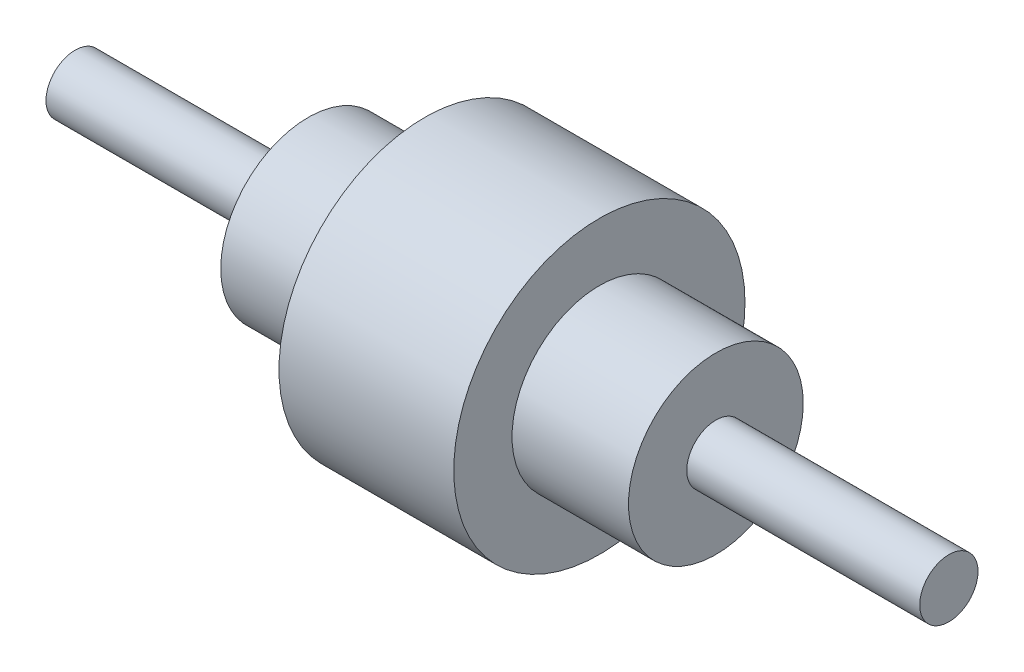
from build123d import *

# Parameters (mm, degrees)
SKETCH1_R           = 50
BOSS_EXTRUDE1_DEPTH = 30
SKETCH2_R           = 30
BOSS_EXTRUDE2_DEPTH = 30
SKETCH3_R           = 10
BOSS_EXTRUDE3_DEPTH = 80
SKETCH7_R           = 30
BOSS_EXTRUDE4_DEPTH = 10
SKETCH8_R           = 10
BOSS_EXTRUDE5_DEPTH = 10
SKETCH9_R           = 30
BOSS_EXTRUDE6_DEPTH = 10
SKETCH10_R          = 10
BOSS_EXTRUDE7_DEPTH = 10


with BuildPart() as part:
    # Sketch1 → Boss-Extrude1 (new body)
    with BuildSketch(Plane(origin=(0, 0, 0), x_dir=(0, 0, -1), z_dir=(1, 0, 0))):
        Circle(SKETCH1_R)
    boss_extrude1 = extrude(amount=BOSS_EXTRUDE1_DEPTH)

    # Sketch2 → Boss-Extrude2 (add)
    with BuildSketch(Plane(origin=(30, 0, 0), x_dir=(0, 0, -1), z_dir=(1, 0, 0))):
        Circle(SKETCH2_R)
    boss_extrude2 = extrude(amount=BOSS_EXTRUDE2_DEPTH)

    # Sketch3 → Boss-Extrude3 (add)
    with BuildSketch(Plane(origin=(60, 0, 0), x_dir=(0, 0, -1), z_dir=(1, 0, 0))):
        Circle(SKETCH3_R)
    boss_extrude3 = extrude(amount=BOSS_EXTRUDE3_DEPTH)

    # Mirror1: Boss-Extrude1, Boss-Extrude2, Boss-Extrude3 across plane
    add(boss_extrude1.mirror(Plane(origin=(0, 0, 0), x_dir=(0, 0, 1), z_dir=(1, 0, 0))))
    add(boss_extrude2.mirror(Plane(origin=(0, 0, 0), x_dir=(0, 0, 1), z_dir=(1, 0, 0))))
    add(boss_extrude3.mirror(Plane(origin=(0, 0, 0), x_dir=(0, 0, 1), z_dir=(1, 0, 0))))

    # Sketch7 → Boss-Extrude4 (add)
    with BuildSketch(Plane.ZY.offset(60)):
        Circle(SKETCH7_R)
    extrude(amount=BOSS_EXTRUDE4_DEPTH)

    # Sketch8 → Boss-Extrude5 (add)
    with BuildSketch(Plane.ZY.offset(140)):
        Circle(SKETCH8_R)
    extrude(amount=BOSS_EXTRUDE5_DEPTH)

    # Sketch9 → Boss-Extrude6 (add)
    with BuildSketch(Plane(origin=(60, 0, 0), x_dir=(0, 0, -1), z_dir=(1, 0, 0))):
        Circle(SKETCH9_R)
    extrude(amount=BOSS_EXTRUDE6_DEPTH)

    # Sketch10 → Boss-Extrude7 (add)
    with BuildSketch(Plane(origin=(140, 0, 0), x_dir=(0, 0, -1), z_dir=(1, 0, 0))):
        Circle(SKETCH10_R)
    extrude(amount=BOSS_EXTRUDE7_DEPTH)


solid = part.part
